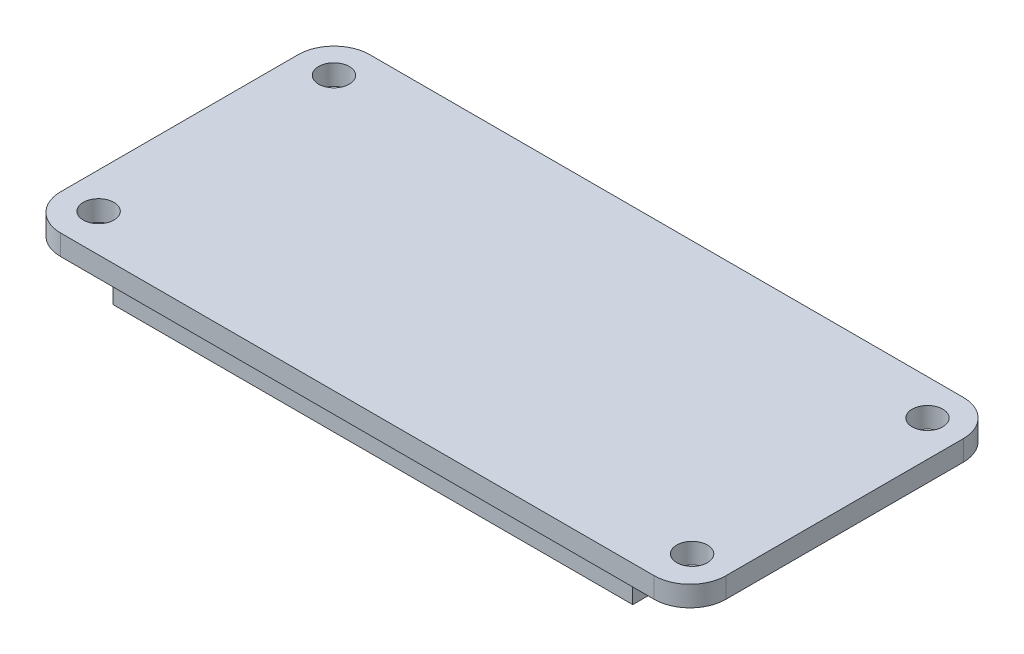
from build123d import *

# Parameters (mm, degrees)
SKETCH_1_W          = 65
SKETCH_1_H          = 30.2
EXTRUDE_1_DEPTH     = 2
SKETCH_2_R          = 1.5
CUT_EXTRUDE_1_DEPTH = 3
FILLET_1_R          = 3.5
SKETCH_4_W          = 50.8
SKETCH_4_H          = 5.08
EXTRUDE_2_DEPTH     = 3


with BuildPart() as part:
    # 草圖1 → 填料-伸長1 (new body)
    with BuildSketch(Plane(origin=(0, 0, 0), x_dir=(1, 0, 0), z_dir=(0, 1, 0))):
        Rectangle(SKETCH_1_W, SKETCH_1_H)
    extrude(amount=EXTRUDE_1_DEPTH)

    # 草圖2 → 除料-伸長1 (cut, through all)
    with BuildSketch(Plane(origin=(0, 2, 0), x_dir=(1, 0, 0), z_dir=(0, 1, 0))):
        with Locations((-29, 11.6)):
            Circle(SKETCH_2_R)
        with Locations((-29, -11.4)):
            Circle(SKETCH_2_R)
        with Locations((29, -11.4)):
            Circle(SKETCH_2_R)
        with Locations((29, 11.6)):
            Circle(SKETCH_2_R)
    extrude(amount=-CUT_EXTRUDE_1_DEPTH, mode=Mode.SUBTRACT)

    # 圓角1
    fillet_1_edges = [part.edges().sort_by_distance(p)[0] for p in [
        (32.5, 1, 15.1),
        (-32.5, 1, 15.1),
        (-32.5, 1, -15.1),
        (32.5, 1, -15.1),
    ]]
    fillet(fillet_1_edges, radius=FILLET_1_R)

    # 草圖4 → 填料-伸長2 (add)
    with BuildSketch(Plane.XZ):
        with Locations((0, 11.06)):
            Rectangle(SKETCH_4_W, SKETCH_4_H)
    extrude(amount=EXTRUDE_2_DEPTH)


solid = part.part
